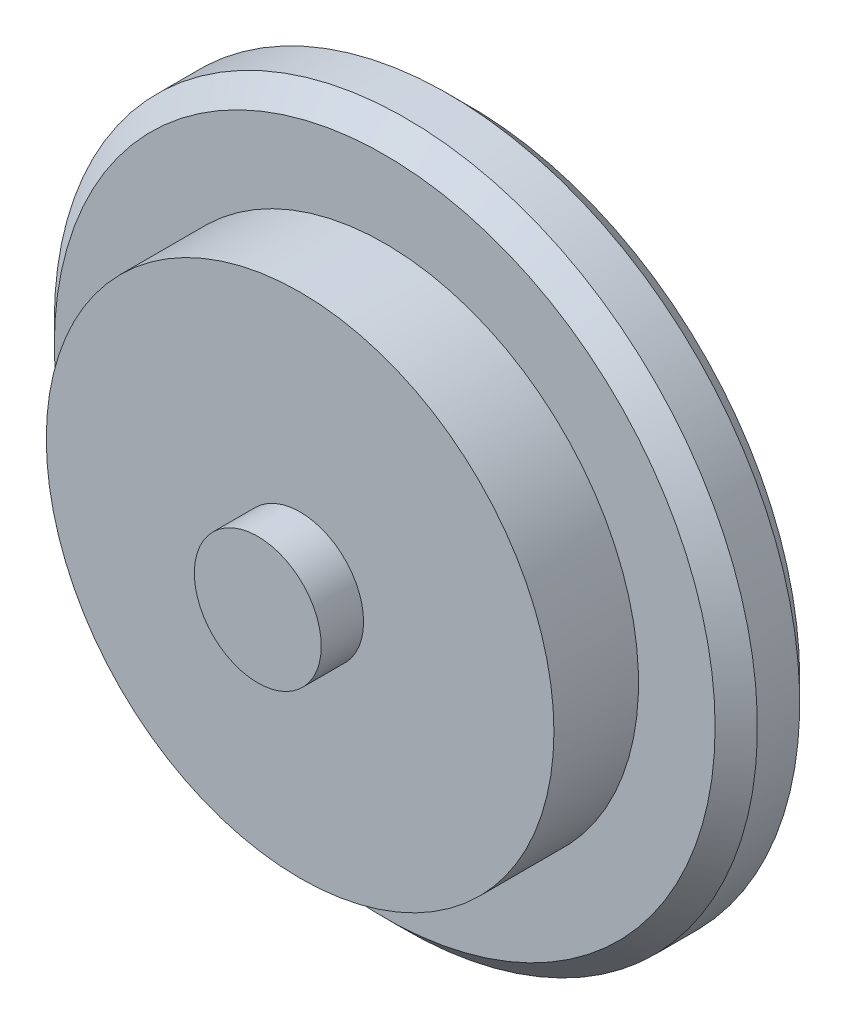
from build123d import *

# Parameters (mm, degrees)
SKETCH1_R           = 76.2
BOSS_EXTRUDE1_DEPTH = 25.4
SKETCH2_R           = 19.05
BOSS_EXTRUDE2_DEPTH = 12.7
SKETCH3_R           = 105.541701
BOSS_EXTRUDE4_DEPTH = 25.4
CHAMFER1_SIZE       = 6.35
SHELL1_T            = -0.635


with BuildPart() as part:
    # Sketch1 → Boss-Extrude1 (new body)
    with BuildSketch(Plane.XY):
        Circle(SKETCH1_R)
    extrude(amount=BOSS_EXTRUDE1_DEPTH)

    # Sketch2 → Boss-Extrude2 (add)
    with BuildSketch(Plane.XY.offset(25.4)):
        Circle(SKETCH2_R)
    extrude(amount=BOSS_EXTRUDE2_DEPTH)

    # Sketch3 → Boss-Extrude4 (add)
    with BuildSketch(Plane(origin=(0, 0, 0), x_dir=(-1, 0, 0), z_dir=(0, 0, -1))):
        Circle(SKETCH3_R)
    extrude(amount=BOSS_EXTRUDE4_DEPTH)

    # Chamfer1
    chamfer1_edges = [part.edges().sort_by_distance(p)[0] for p in [
        (105.541701, 0, 0),
        (105.541701, 0, -25.4),
    ]]
    chamfer(chamfer1_edges, length=CHAMFER1_SIZE)

    # Shell1
    shell1_openings = [part.faces().sort_by_distance(p)[0] for p in [
        (-99.191701, 0, -25.4),
    ]]
    offset(amount=SHELL1_T, openings=shell1_openings, kind=Kind.INTERSECTION)


solid = part.part
